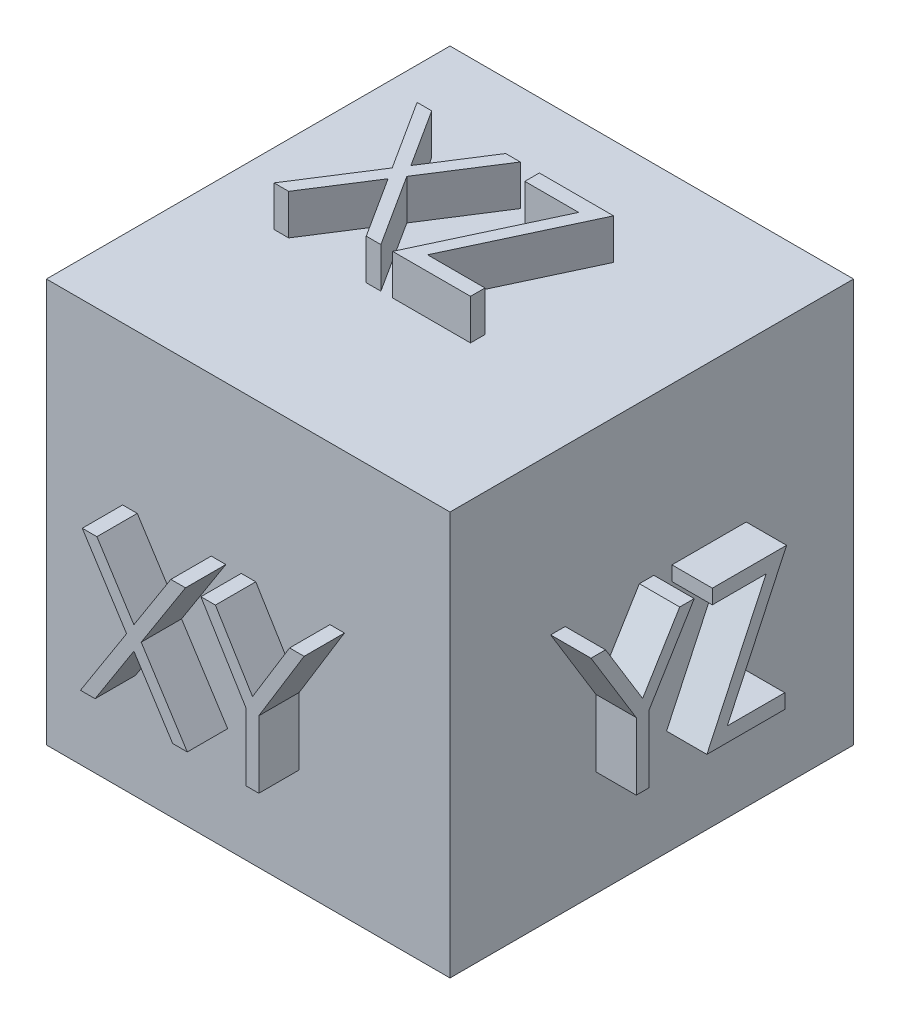
from build123d import *

# Parameters (mm, degrees)
SKETCH1_W           = 10
SKETCH1_H           = 10
BOSS_EXTRUDE1_DEPTH = 10
BOSS_EXTRUDE2_DEPTH = 1
BOSS_EXTRUDE3_DEPTH = 1
BOSS_EXTRUDE4_DEPTH = 1


with BuildPart() as part:
    # Sketch1 → Boss-Extrude1 (new body)
    with BuildSketch(Plane(origin=(0, 0, 0), x_dir=(1, 0, 0), z_dir=(0, 1, 0))):
        with Locations((5, 5)):
            Rectangle(SKETCH1_W, SKETCH1_H)
    extrude(amount=BOSS_EXTRUDE1_DEPTH)

    # Sketch2 → Boss-Extrude2 (add)
    with BuildSketch(Plane.XY):
        Polygon((1.888096604, 6.09581066), (2.250576572, 6.09581066), (3.166942757, 4.664119955), (4.083308943, 6.09581066), (4.445788911, 6.09581066), (3.348533302, 4.38086675), (4.490660706, 2.59581066), (4.128180738, 2.59581066), (3.166942757, 4.097613545), (2.205704777, 2.59581066), (1.843224809, 2.59581066), (2.986053334, 4.38086675), align=None)
        Polygon((4.827199168, 6.09581066), (5.186874649, 6.09581066), (6.106746443, 4.59190441), (7.025215995, 6.09581066), (7.384891475, 6.09581066), (6.263096604, 4.25957268), (6.263096604, 2.59581066), (5.94899404, 2.59581066), (5.94899404, 4.25957268), align=None)
    extrude(amount=BOSS_EXTRUDE2_DEPTH)

    # Sketch3 → Boss-Extrude3 (add)
    with BuildSketch(Plane(origin=(0, 10, 0), x_dir=(1, 0, 0), z_dir=(0, 1, 0))):
        Polygon((1.802209363, 7.38229402), (2.164689331, 7.38229402), (3.081055517, 5.950603315), (3.997421703, 7.38229402), (4.359901671, 7.38229402), (3.262646062, 5.667350109), (4.404773466, 3.88229402), (4.042293498, 3.88229402), (3.081055517, 5.384096904), (2.119817536, 3.88229402), (1.757337568, 3.88229402), (2.900166094, 5.667350109), align=None)
        Polygon((4.831055517, 7.023319661), (4.831055517, 7.38229402), (6.670799107, 7.38229402), (5.202650068, 4.241268379), (6.625927312, 4.241268379), (6.625927312, 3.88229402), (4.696440132, 3.88229402), (6.164589171, 7.023319661), align=None)
    extrude(amount=BOSS_EXTRUDE3_DEPTH)

    # Sketch4 → Boss-Extrude4 (add)
    with BuildSketch(Plane(origin=(10, 0, 0), x_dir=(0, 0, -1), z_dir=(1, 0, 0))):
        Polygon((2.493902055, 6.115757789), (2.853577536, 6.115757789), (3.773449331, 4.611851539), (4.691918882, 6.115757789), (5.051594363, 6.115757789), (3.929799491, 4.279519808), (3.929799491, 2.615757789), (3.615696927, 2.615757789), (3.615696927, 4.279519808), align=None)
        Polygon((5.500312311, 5.75678343), (5.500312311, 6.115757789), (7.340055901, 6.115757789), (5.871906863, 2.974732148), (7.295184106, 2.974732148), (7.295184106, 2.615757789), (5.365696927, 2.615757789), (6.833845965, 5.75678343), align=None)
    extrude(amount=BOSS_EXTRUDE4_DEPTH)


solid = part.part
